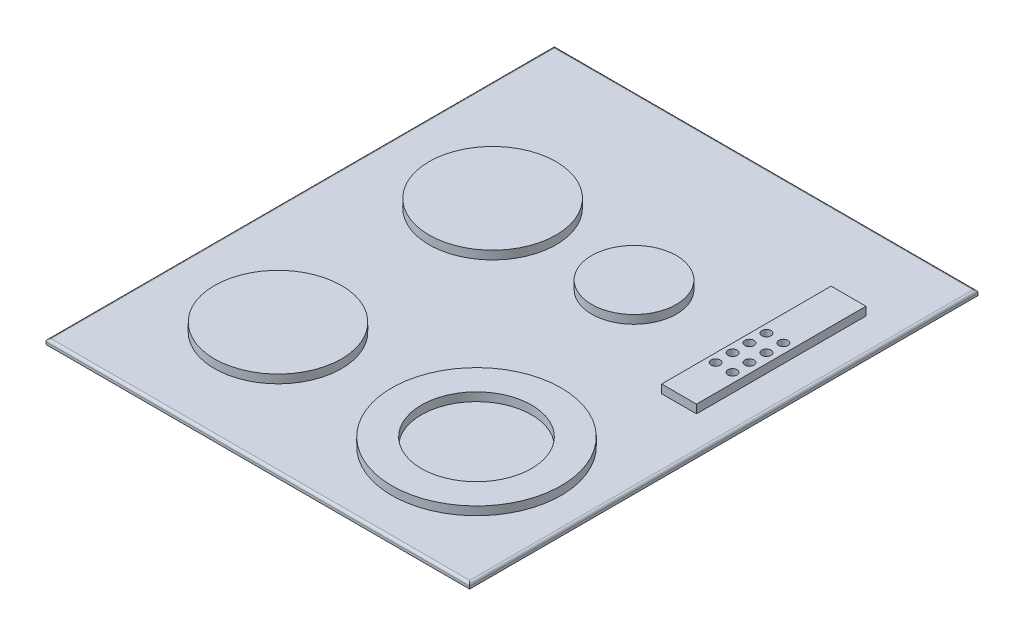
from build123d import *

# Parameters (mm, degrees)
SKETCH1_W           = 500
SKETCH1_H           = 600
BOSS_EXTRUDE1_DEPTH = 6
FILLET1_R           = 3
SKETCH3_W           = 400
SKETCH3_H           = 500
BOSS_EXTRUDE2_DEPTH = 26
SKETCH2_R           = 75
SKETCH2_R_2         = 50
SKETCH2_R_3         = 100
SKETCH2_R_4         = 65
SKETCH2_W           = 41.104529262
SKETCH2_H           = 200
SKETCH2_R_5         = 5.399416509
BOSS_EXTRUDE3_DEPTH = 10
SKETCH4_R           = 53.966181138
BOSS_EXTRUDE4_DEPTH = 1


with BuildPart() as part:
    # Sketch1 → Boss-Extrude1 (new body)
    with BuildSketch(Plane(origin=(0, 0, 0), x_dir=(1, 0, 0), z_dir=(0, 1, 0))):
        with Locations((250, 300)):
            Rectangle(SKETCH1_W, SKETCH1_H)
    extrude(amount=BOSS_EXTRUDE1_DEPTH)

    # Fillet1
    fillet1_edges = [part.edges().sort_by_distance(p)[0] for p in [
        (500, 6, -300),
        (250, 6, -600),
        (0, 6, -300),
        (250, 6, 0),
    ]]
    fillet(fillet1_edges, radius=FILLET1_R)

    # Sketch3 → Boss-Extrude2 (add)
    with BuildSketch(Plane.XZ):
        with Locations((250, -300)):
            Rectangle(SKETCH3_W, SKETCH3_H)
    extrude(amount=BOSS_EXTRUDE2_DEPTH)

    # Sketch2 → Boss-Extrude3 (add)
    with BuildSketch(Plane(origin=(0, 6, 0), x_dir=(1, 0, 0), z_dir=(0, 1, 0))):
        with Locations((130.089337479, 397)):
            Circle(SKETCH2_R)
        with Locations((297, 397)):
            Circle(SKETCH2_R_2)
        with Locations((130.089337479, 143.740125968)):
            Circle(SKETCH2_R)
        with Locations((364.330089408, 143.740125968)):
            Circle(SKETCH2_R_3)
        with Locations((364.330089408, 143.740125968)):
            Circle(SKETCH2_R_4, mode=Mode.SUBTRACT)
        with Locations((440.198970532, 407)):
            Rectangle(SKETCH2_W, SKETCH2_H)
        with Locations((449.543954361, 420.752043301)):
            Circle(SKETCH2_R_5, mode=Mode.SUBTRACT)
        with Locations((429.543954361, 420.752043301)):
            Circle(SKETCH2_R_5, mode=Mode.SUBTRACT)
        with Locations((429.543954361, 400.752043301)):
            Circle(SKETCH2_R_5, mode=Mode.SUBTRACT)
        with Locations((429.543954361, 380.752043301)):
            Circle(SKETCH2_R_5, mode=Mode.SUBTRACT)
        with Locations((429.543954361, 360.752043301)):
            Circle(SKETCH2_R_5, mode=Mode.SUBTRACT)
        with Locations((449.543954361, 400.752043301)):
            Circle(SKETCH2_R_5, mode=Mode.SUBTRACT)
        with Locations((449.543954361, 380.752043301)):
            Circle(SKETCH2_R_5, mode=Mode.SUBTRACT)
        with Locations((449.543954361, 360.752043301)):
            Circle(SKETCH2_R_5, mode=Mode.SUBTRACT)
    extrude(amount=BOSS_EXTRUDE3_DEPTH)

    # Sketch4 → Boss-Extrude4 (add)
    with BuildSketch(Plane.XZ.offset(26)):
        with Locations((250, -300)):
            Circle(SKETCH4_R)
    extrude(amount=BOSS_EXTRUDE4_DEPTH)


solid = part.part
